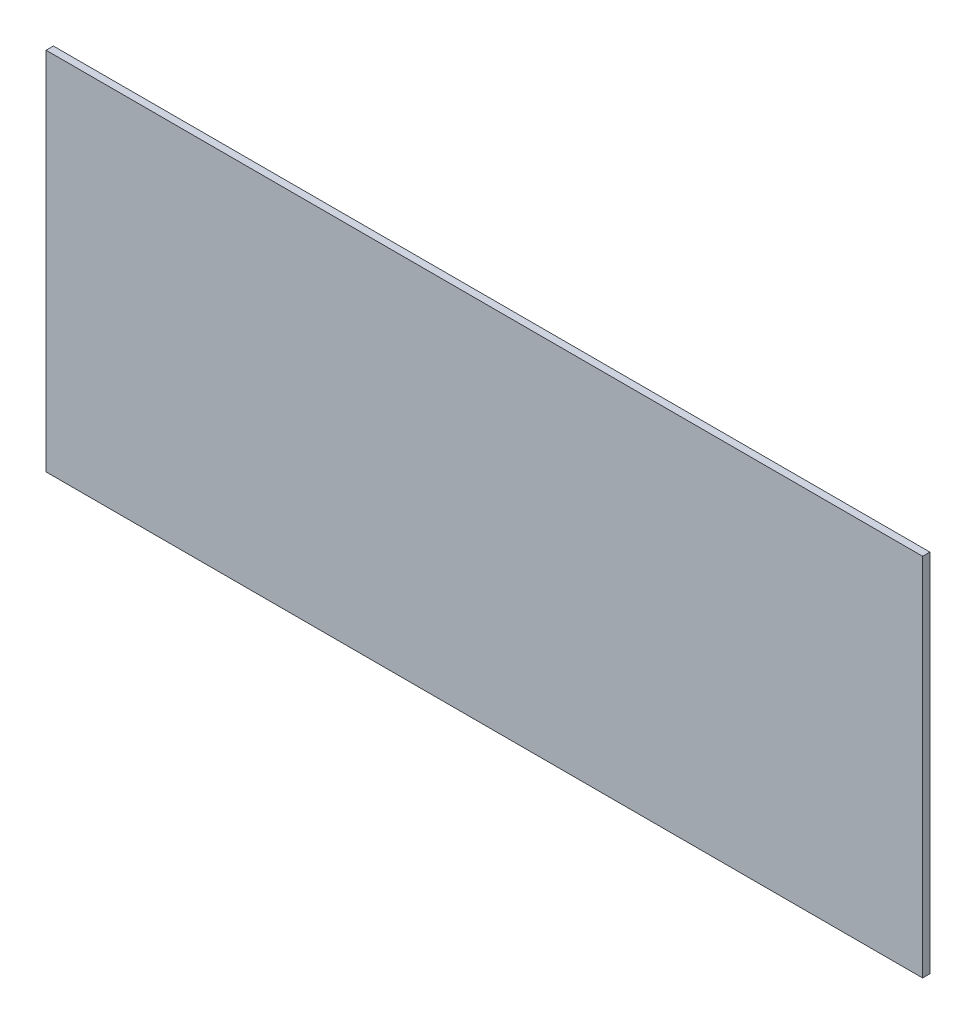
from build123d import *

# Parameters (mm, degrees)
SKETCH1_W           = 240
SKETCH1_H           = 100
BOSS_EXTRUDE1_DEPTH = 2


with BuildPart() as part:
    # Sketch1 → Boss-Extrude1 (new body)
    with BuildSketch(Plane.XY):
        with Locations((120, 50)):
            Rectangle(SKETCH1_W, SKETCH1_H)
    extrude(amount=BOSS_EXTRUDE1_DEPTH)


solid = part.part
